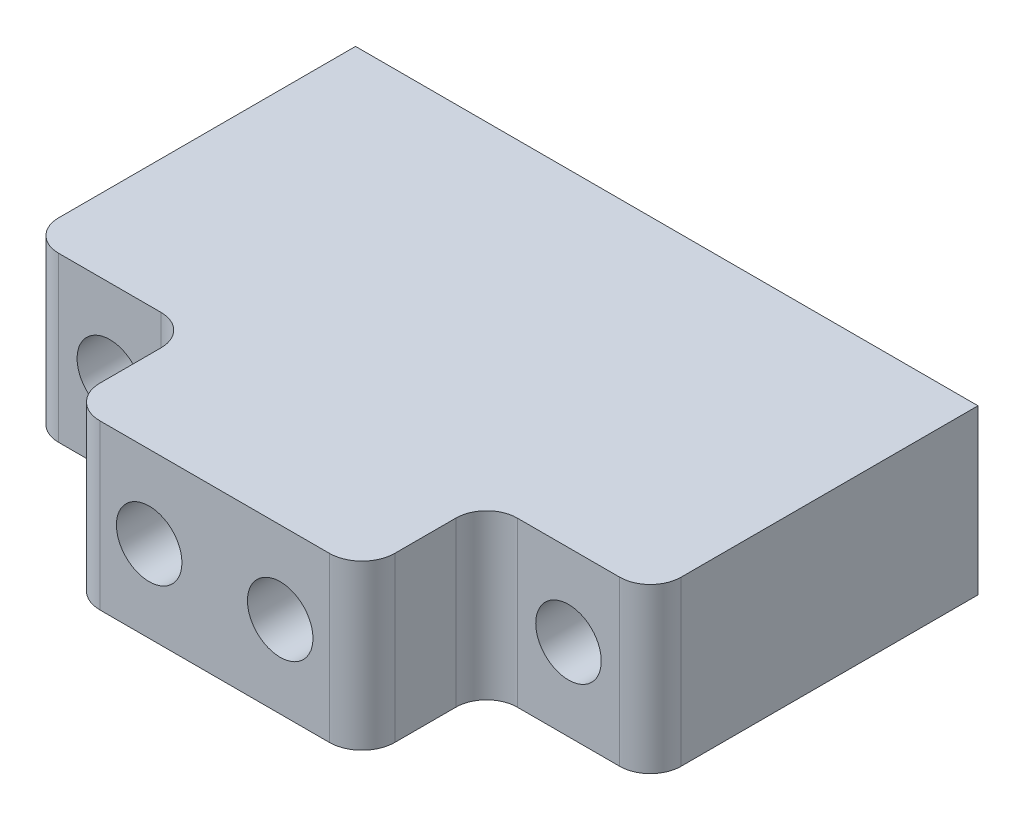
from build123d import *

# Parameters (mm, degrees)
SKETCH1_W            = 48.26
SKETCH1_H            = 12.7
SKETCH1_R            = 2.54
BOSS_EXTRUDE2_DEPTH  = 5.08
SKETCH3_R            = 2.54
CUT_EXTRUDE1_DEPTH   = 6.08
SKETCH4_W            = 3.81
SKETCH4_H            = 12.7
BOSS_EXTRUDE5_DEPTH  = 27.94
SKETCH5_W            = 3.81
SKETCH5_H            = 12.7
BOSS_EXTRUDE6_DEPTH  = 27.94
SKETCH7_W            = 22.86
SKETCH7_H            = 12.7
BOSS_EXTRUDE8_DEPTH  = 2.032
SKETCH10_R           = 2.54
CUT_EXTRUDE4_DEPTH   = 2.032
SKETCH11_R           = 2.54
CUT_EXTRUDE5_DEPTH   = 2.032
FILLET12_R           = 2.54
SKETCH12_W           = 15.24
SKETCH12_H           = 12.7
BOSS_EXTRUDE9_DEPTH  = 27.94
SKETCH13_R           = 2.54
CUT_EXTRUDE6_DEPTH   = 7.493
SKETCH14_R           = 2.54
CUT_EXTRUDE7_DEPTH   = 7.493
SKETCH20_R           = 4.8006
CUT_EXTRUDE13_DEPTH  = 3.429
SKETCH21_W           = 12.7
SKETCH21_H           = 12.7
BOSS_EXTRUDE10_DEPTH = 20.32
SKETCH22_R           = 2.54
CUT_EXTRUDE14_DEPTH  = 20.32
SKETCH23_W           = 12.7
SKETCH23_H           = 12.7
BOSS_EXTRUDE11_DEPTH = 20.32
SKETCH24_R           = 2.54
CUT_EXTRUDE15_DEPTH  = 25.4
SKETCH26_R           = 4.8006
CUT_EXTRUDE16_DEPTH  = 3.429
FILLET15_R           = 2.38
FILLET16_R           = 2.38
FILLET17_R           = 2.38


with BuildPart() as part:
    # Sketch1 → Boss-Extrude2 (new body)
    with BuildSketch(Plane.XY):
        Rectangle(SKETCH1_W, SKETCH1_H)
        with Locations((-17.78, 0)):
            Circle(SKETCH1_R, mode=Mode.SUBTRACT)
    extrude(amount=-BOSS_EXTRUDE2_DEPTH)

    # Sketch3 → Cut-Extrude1 (cut, through all)
    with BuildSketch(Plane.XY):
        with Locations((17.78, 0)):
            Circle(SKETCH3_R)
    extrude(amount=-CUT_EXTRUDE1_DEPTH, mode=Mode.SUBTRACT)

    # Sketch4 → Boss-Extrude5 (add)
    with BuildSketch(Plane.XY):
        with Locations((-9.525, 0)):
            Rectangle(SKETCH4_W, SKETCH4_H)
    extrude(amount=BOSS_EXTRUDE5_DEPTH)

    # Sketch5 → Boss-Extrude6 (add)
    with BuildSketch(Plane.XY):
        with Locations((9.525, 0)):
            Rectangle(SKETCH5_W, SKETCH5_H)
    extrude(amount=BOSS_EXTRUDE6_DEPTH)

    # Sketch7 → Boss-Extrude8 (add)
    with BuildSketch(Plane.XY.offset(27.94)):
        Rectangle(SKETCH7_W, SKETCH7_H)
    extrude(amount=BOSS_EXTRUDE8_DEPTH)

    # Sketch10 → Cut-Extrude4 (cut)
    with BuildSketch(Plane.XY.offset(29.972)):
        with Locations((-5.08, 0)):
            Circle(SKETCH10_R)
    extrude(amount=-CUT_EXTRUDE4_DEPTH, mode=Mode.SUBTRACT)

    # Sketch11 → Cut-Extrude5 (cut)
    with BuildSketch(Plane.XY.offset(29.972)):
        with Locations((5.08, 0)):
            Circle(SKETCH11_R)
    extrude(amount=-CUT_EXTRUDE5_DEPTH, mode=Mode.SUBTRACT)

    # Fillet12
    fillet12_edges = [part.edges().sort_by_distance(p)[0] for p in [
        (-11.43, 0, 29.972),
        (11.43, 0, 29.972),
    ]]
    fillet(fillet12_edges, radius=FILLET12_R)

    # Sketch12 → Boss-Extrude9 (add)
    with BuildSketch(Plane.XY):
        Rectangle(SKETCH12_W, SKETCH12_H)
    extrude(amount=BOSS_EXTRUDE9_DEPTH)

    # Sketch13 → Cut-Extrude6 (cut)
    with BuildSketch(Plane.XY.offset(27.94)):
        with Locations((-5.08, 0)):
            Circle(SKETCH13_R)
    extrude(amount=-CUT_EXTRUDE6_DEPTH, mode=Mode.SUBTRACT)

    # Sketch14 → Cut-Extrude7 (cut)
    with BuildSketch(Plane.XY.offset(27.94)):
        with Locations((5.08, 0)):
            Circle(SKETCH14_R)
    extrude(amount=-CUT_EXTRUDE7_DEPTH, mode=Mode.SUBTRACT)

    # Sketch20 → Cut-Extrude13 (cut)
    with BuildSketch(Plane(origin=(0, 0, -5.08), x_dir=(-1, 0, 0), z_dir=(0, 0, -1))):
        with Locations((17.78, 0)):
            Circle(SKETCH20_R)
    extrude(amount=-CUT_EXTRUDE13_DEPTH, mode=Mode.SUBTRACT)

    # Sketch21 → Boss-Extrude10 (add)
    with BuildSketch(Plane.XY):
        with Locations((-17.78, 0)):
            Rectangle(SKETCH21_W, SKETCH21_H)
    extrude(amount=BOSS_EXTRUDE10_DEPTH)

    # Sketch22 → Cut-Extrude14 (cut)
    with BuildSketch(Plane(origin=(0, 0, 0), x_dir=(-1, 0, 0), z_dir=(0, 0, -1))):
        with Locations((17.78, 0)):
            Circle(SKETCH22_R)
    extrude(amount=-CUT_EXTRUDE14_DEPTH, mode=Mode.SUBTRACT)

    # Sketch23 → Boss-Extrude11 (add)
    with BuildSketch(Plane.XY):
        with Locations((17.78, 0)):
            Rectangle(SKETCH23_W, SKETCH23_H)
    extrude(amount=BOSS_EXTRUDE11_DEPTH)

    # Sketch24 → Cut-Extrude15 (cut)
    with BuildSketch(Plane(origin=(0, 0, -5.08), x_dir=(-1, 0, 0), z_dir=(0, 0, -1))):
        with Locations((-17.78, 0)):
            Circle(SKETCH24_R)
    extrude(amount=-CUT_EXTRUDE15_DEPTH, mode=Mode.SUBTRACT)

    # Sketch26 → Cut-Extrude16 (cut)
    with BuildSketch(Plane(origin=(0, 0, -5.08), x_dir=(-1, 0, 0), z_dir=(0, 0, -1))):
        with Locations((-17.78, 0)):
            Circle(SKETCH26_R)
    extrude(amount=-CUT_EXTRUDE16_DEPTH, mode=Mode.SUBTRACT)

    # Fillet15
    fillet15_edges = [part.edges().sort_by_distance(p)[0] for p in [
        (11.43, 0, 20.32),
    ]]
    fillet(fillet15_edges, radius=FILLET15_R)

    # Fillet16
    fillet16_edges = [part.edges().sort_by_distance(p)[0] for p in [
        (-11.43, 0, 20.32),
    ]]
    fillet(fillet16_edges, radius=FILLET16_R)

    # Fillet17
    fillet17_edges = [part.edges().sort_by_distance(p)[0] for p in [
        (-24.13, 0, 20.32),
        (24.13, 0, 20.32),
    ]]
    fillet(fillet17_edges, radius=FILLET17_R)


solid = part.part
